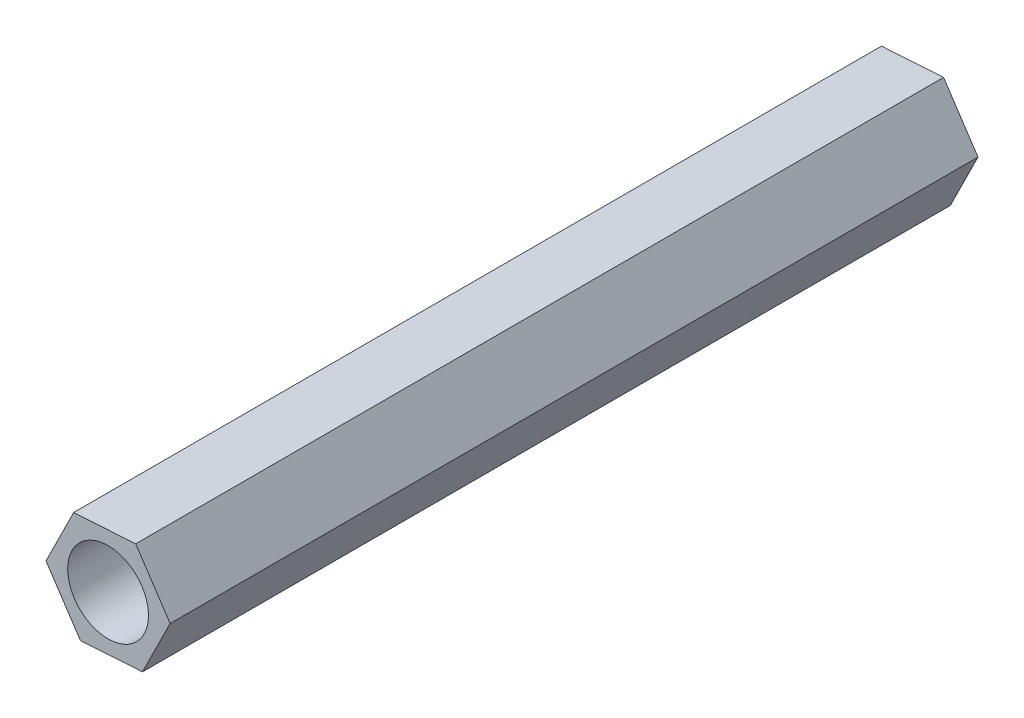
from build123d import *

# Parameters (mm, degrees)
EXTRUDE_1_DEPTH     = 30
SKETCH_2_R          = 1.5
CUT_EXTRUDE_1_DEPTH = 31


with BuildPart() as part:
    # 草图1 → 凸台-拉伸1 (new body)
    with BuildSketch(Plane.XY):
        Polygon((1.026274392, 2.068838854), (-1.278529808, 1.923199122), (-2.3048042, -0.145639732), (-1.026274392, -2.068838854), (1.278529808, -1.923199122), (2.3048042, 0.145639732), align=None)
    extrude(amount=EXTRUDE_1_DEPTH)

    # 草图2 → 切除-拉伸1 (cut, through all)
    with BuildSketch(Plane(origin=(0, 0, 0), x_dir=(-1, 0, 0), z_dir=(0, 0, -1))):
        Circle(SKETCH_2_R)
    extrude(amount=-CUT_EXTRUDE_1_DEPTH, mode=Mode.SUBTRACT)


solid = part.part
